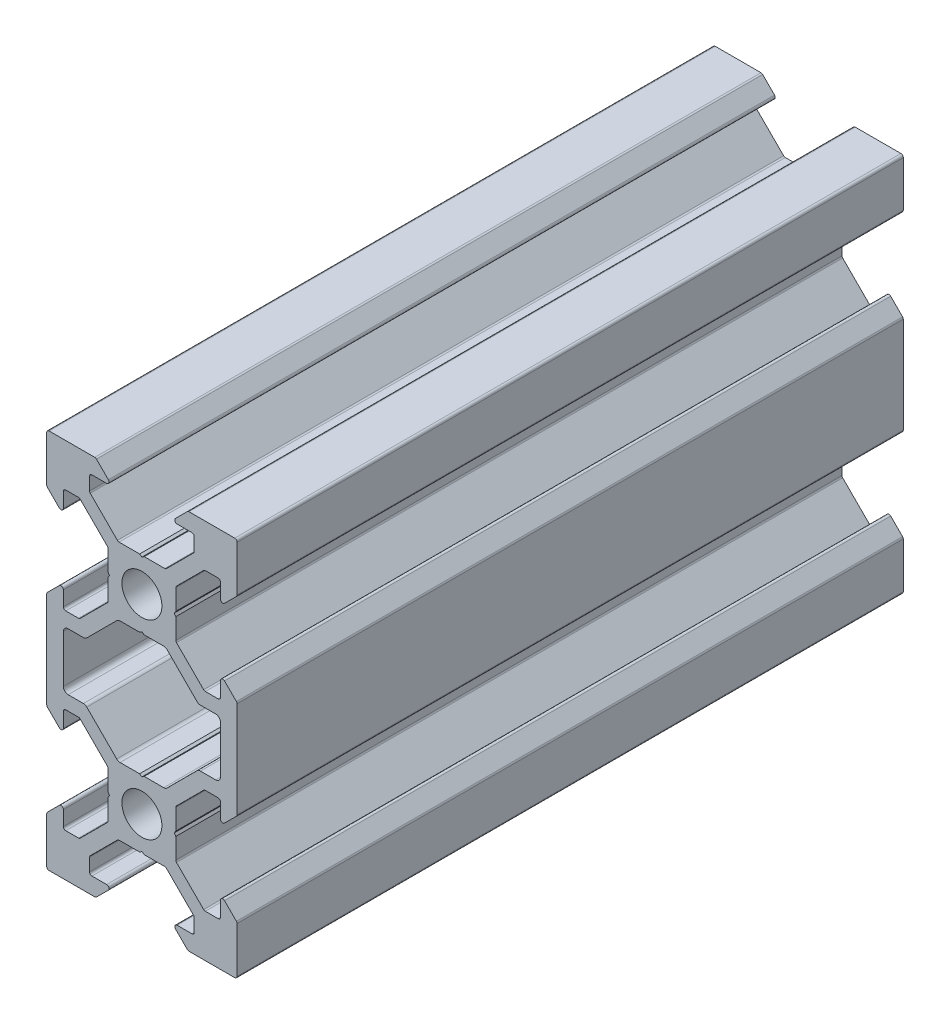
from build123d import *

# Parameters (mm, degrees)
SKETCH1_R           = 2.1
BOSS_EXTRUDE1_DEPTH = 70
FILLET1_R           = 0.25
FILLET2_R           = 0.5
CUT_EXTRUDE1_DEPTH  = 71


with BuildPart() as part:
    # Sketch1 → Boss-Extrude1 (new body)
    with BuildSketch(Plane.XY):
        Polygon((3.560660172, -2.5), (3.560660172, 2.5), (6.560660172, 5.5), (8.252142372, 5.5), (8.252142372, 3.1), (10, 4.847857628), (10, 10), (4.847857628, 10), (3.1, 8.252142372), (5.5, 8.252142372), (5.5, 6.560660172), (2.5, 3.560660172), (-2.5, 3.560660172), (-5.5, 6.560660172), (-5.5, 8.252142372), (-3.1, 8.252142372), (-4.847857628, 10), (-10, 10), (-10, 4.847857628), (-8.252142372, 3.1), (-8.252142372, 5.5), (-6.560660172, 5.5), (-3.560660172, 2.5), (-3.560660172, -2.5), (-6.560660172, -5.5), (-8.252142372, -5.5), (-8.252142372, -3.1), (-10, -4.847857628), (-10, -7), (-10, -13), (-10, -15.152142372), (-8.252142372, -16.9), (-8.252142372, -14.5), (-6.560660172, -14.5), (-3.560660172, -17.5), (-3.560660172, -22.5), (-6.560660172, -25.5), (-8.252142372, -25.5), (-8.252142372, -23.1), (-10, -24.847857628), (-10, -30), (-4.847857628, -30), (-3.1, -28.252142372), (-5.5, -28.252142372), (-5.5, -26.560660172), (-2.5, -23.560660172), (2.5, -23.560660172), (5.5, -26.560660172), (5.5, -28.252142372), (3.1, -28.252142372), (4.847857628, -30), (10, -30), (10, -24.847857628), (8.252142372, -23.1), (8.252142372, -25.5), (6.560660172, -25.5), (3.560660172, -22.5), (3.560660172, -17.5), (6.560660172, -14.5), (8.252142372, -14.5), (8.252142372, -16.9), (10, -15.152142372), (10, -13), (10, -7), (10, -4.847857628), (8.252142372, -3.1), (8.252142372, -5.5), (6.560660172, -5.5), align=None)
        Circle(SKETCH1_R, mode=Mode.SUBTRACT)
        with Locations((0, -20)):
            Circle(SKETCH1_R, mode=Mode.SUBTRACT)
        Polygon((2.5, -3.560660172), (-2.5, -3.560660172), (-5.5, -6.560660172), (-5.939339828, -7), (-8.252142372, -7), (-8.252142372, -13), (-5.939339828, -13), (-5.5, -13.439339828), (-2.5, -16.439339828), (2.5, -16.439339828), (5.5, -13.439339828), (5.939339828, -13), (8.252142372, -13), (8.252142372, -7), (5.939339828, -7), (5.5, -6.560660172), align=None, mode=Mode.SUBTRACT)
    extrude(amount=BOSS_EXTRUDE1_DEPTH)

    # Fillet1
    fillet1_edges = [part.edges().sort_by_distance(p)[0] for p in [
        (5.5, 6.560660172, 35),
        (5.5, 8.252142372, 35),
        (3.1, 8.252142372, 35),
        (4.847857628, 10, 35),
        (10, 10, 35),
        (10, 4.847857628, 35),
        (8.252142372, 3.1, 35),
        (8.252142372, 5.5, 35),
        (6.560660172, 5.5, 35),
        (3.560660172, 2.5, 35),
        (3.560660172, -2.5, 35),
        (6.560660172, -5.5, 35),
        (8.252142372, -5.5, 35),
        (8.252142372, -3.1, 35),
        (10, -4.847857628, 35),
        (10, -15.152142372, 35),
        (8.252142372, -16.9, 35),
        (8.252142372, -14.5, 35),
        (6.560660172, -14.5, 35),
        (3.560660172, -17.5, 35),
        (3.560660172, -22.5, 35),
        (6.560660172, -25.5, 35),
        (8.252142372, -25.5, 35),
        (8.252142372, -23.1, 35),
        (10, -24.847857628, 35),
        (10, -30, 35),
        (4.847857628, -30, 35),
        (3.1, -28.252142372, 35),
        (5.5, -28.252142372, 35),
        (5.5, -26.560660172, 35),
        (2.5, -23.560660172, 35),
        (-2.5, -23.560660172, 35),
        (-5.5, -26.560660172, 35),
        (-5.5, -28.252142372, 35),
        (-3.1, -28.252142372, 35),
        (-4.847857628, -30, 35),
        (-10, -30, 35),
        (-10, -24.847857628, 35),
        (-8.252142372, -23.1, 35),
        (-8.252142372, -25.5, 35),
        (-6.560660172, -25.5, 35),
        (-3.560660172, -22.5, 35),
        (-3.560660172, -17.5, 35),
        (-6.560660172, -14.5, 35),
        (-8.252142372, -14.5, 35),
        (-8.252142372, -16.9, 35),
        (-10, -15.152142372, 35),
        (-10, -4.847857628, 35),
        (-8.252142372, -3.1, 35),
        (-8.252142372, -5.5, 35),
        (-6.560660172, -5.5, 35),
        (-3.560660172, -2.5, 35),
        (-3.560660172, 2.5, 35),
        (-6.560660172, 5.5, 35),
        (-8.252142372, 5.5, 35),
        (-8.252142372, 3.1, 35),
        (-10, 4.847857628, 35),
        (-10, 10, 35),
        (-4.847857628, 10, 35),
        (-3.1, 8.252142372, 35),
        (-5.5, 8.252142372, 35),
        (-5.5, 6.560660172, 35),
        (-2.5, 3.560660172, 35),
        (2.5, 3.560660172, 35),
    ]]
    fillet(fillet1_edges, radius=FILLET1_R)

    # Fillet2
    fillet2_edges = [part.edges().sort_by_distance(p)[0] for p in [
        (-2.5, -3.560660172, 35),
        (-5.939339828, -7, 35),
        (-8.252142372, -7, 35),
        (-8.252142372, -13, 35),
        (-5.939339828, -13, 35),
        (-2.5, -16.439339828, 35),
        (2.5, -16.439339828, 35),
        (5.939339828, -13, 35),
        (8.252142372, -13, 35),
        (8.252142372, -7, 35),
        (5.939339828, -7, 35),
        (2.5, -3.560660172, 35),
    ]]
    fillet(fillet2_edges, radius=FILLET2_R)

    # Sketch2 → Cut-Extrude1 (cut, through all)
    with BuildSketch(Plane.XY.offset(70)):
        Polygon((0, 3.398953432), (-0.242280927, 3.560660172), (0.242280927, 3.560660172), align=None)
        Polygon((0, -3.398953432), (0.242280927, -3.560660172), (-0.242280927, -3.560660172), align=None)
        Polygon((3.560660172, 0.242280927), (3.560660172, -0.242280927), (3.398953432, 0), align=None)
        Polygon((-3.560660172, 0.242280927), (-3.560660172, -0.242280927), (-3.398953432, 0), align=None)
        Polygon((-3.398953432, -20), (-3.560660172, -20.242280927), (-3.560660172, -19.757719073), align=None)
        Polygon((3.398953432, -20), (3.560660172, -19.757719073), (3.560660172, -20.242280927), align=None)
        Polygon((-0.242280927, -16.439339828), (0.242280927, -16.439339828), (0, -16.601046568), align=None)
        Polygon((-0.242280927, -23.560660172), (0.242280927, -23.560660172), (0, -23.398953432), align=None)
    extrude(amount=-CUT_EXTRUDE1_DEPTH, mode=Mode.SUBTRACT)


solid = part.part
